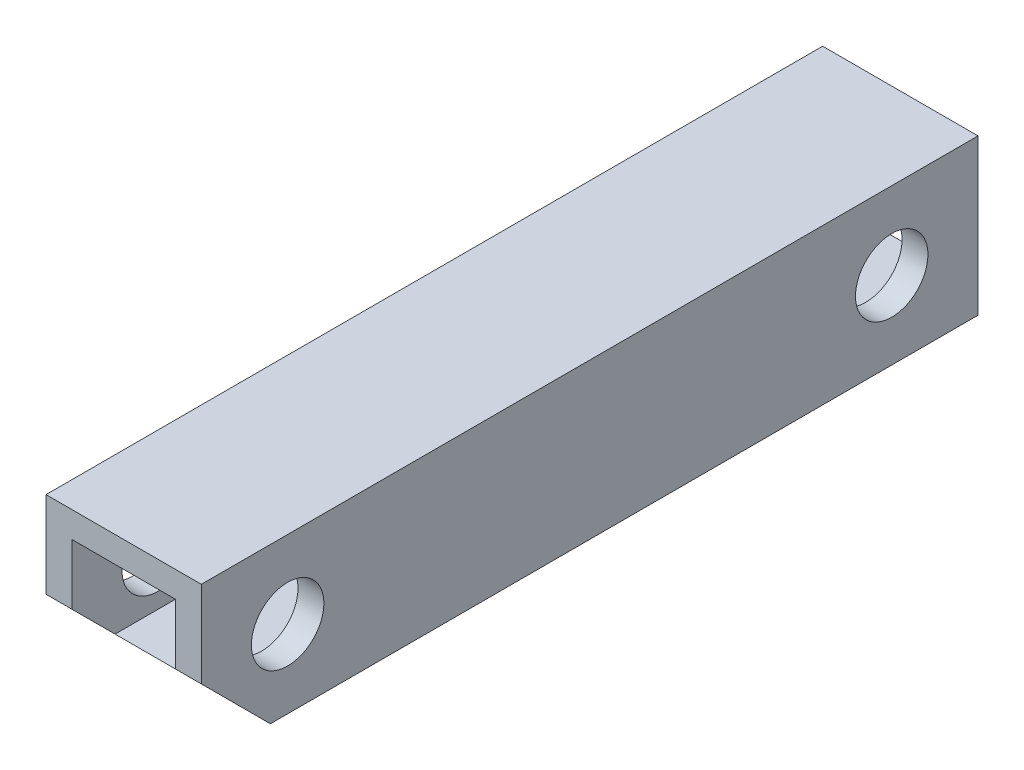
from build123d import *

# Parameters (mm, degrees)
SKETCH_1_W          = 9
SKETCH_1_H          = 9
SKETCH_1_W_2        = 6
SKETCH_1_H_2        = 6
EXTRUDE_1_DEPTH     = 45
SKETCH_2_R          = 2.1
CUT_EXTRUDE_1_DEPTH = 30
CUT_EXTRUDE_3_DEPTH = 10


with BuildPart() as part:
    # ｽｹｯﾁ1 → ﾎﾞｽ - 押し出し1 (new body)
    with BuildSketch(Plane.XY):
        Rectangle(SKETCH_1_W, SKETCH_1_H)
        Rectangle(SKETCH_1_W_2, SKETCH_1_H_2, mode=Mode.SUBTRACT)
    extrude(amount=EXTRUDE_1_DEPTH)

    # ｽｹｯﾁ2 → ｶｯﾄ - 押し出し1 (cut)
    with BuildSketch(Plane(origin=(4.5, 0, 0), x_dir=(0, 0, -1), z_dir=(1, 0, 0))):
        with Locations((-40, 0)):
            Circle(SKETCH_2_R)
        with Locations((-5, 0)):
            Circle(SKETCH_2_R)
    extrude(amount=-CUT_EXTRUDE_1_DEPTH, mode=Mode.SUBTRACT)

    # ｽｹｯﾁ3 → ｶｯﾄ - 押し出し3 (cut)
    with BuildSketch(Plane(origin=(4.5, 0, 0), x_dir=(0, 0, -1), z_dir=(1, 0, 0))):
        Polygon((-45, -4.5), (-45, -0.5), (-41, -4.5), align=None)
    extrude(amount=-CUT_EXTRUDE_3_DEPTH, mode=Mode.SUBTRACT)


solid = part.part
